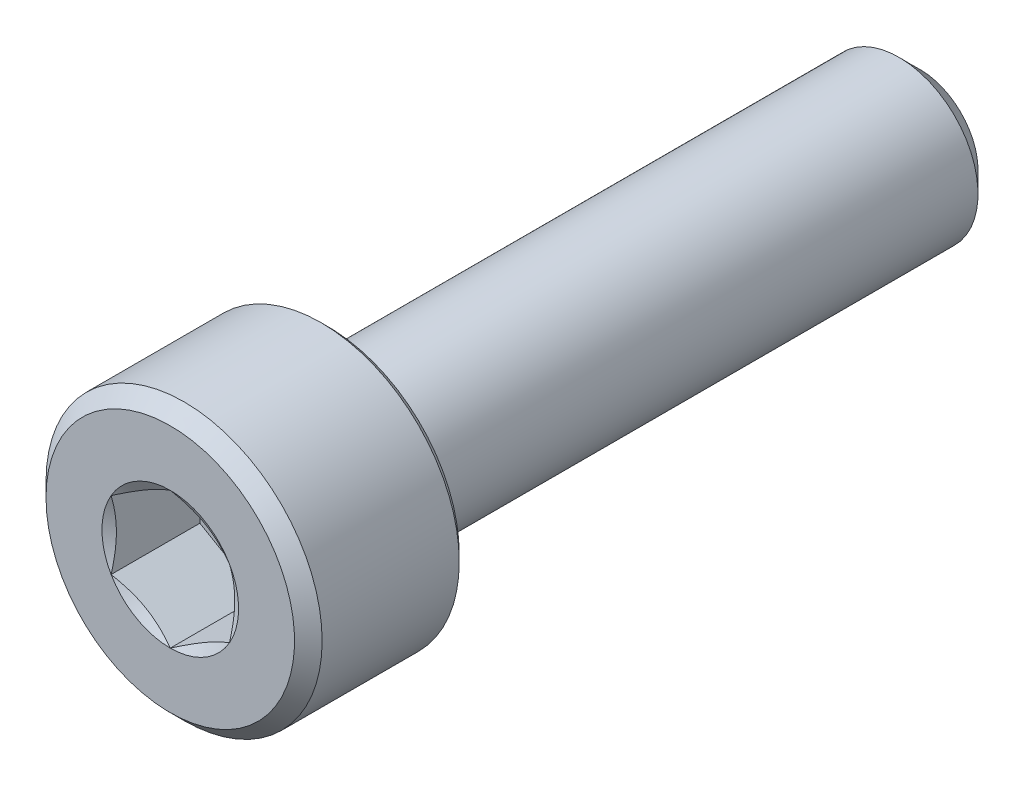
from build123d import *

# Parameters (mm, degrees)
CUT_EXTRUDE1_DEPTH = 2.25
CHAMFER1_SIZE      = 0.35
CHAMFER2_SIZE      = 0.175


with BuildPart() as part:
    # Sketch2 → Revolve1 (revolve)
    with BuildSketch(Plane(origin=(0, 0, 0), x_dir=(0, 0, -1), z_dir=(1, 0, 0))):
        Polygon((9.5, 1.475), (8.975, 2), (-5.5, 2), (-5.5, 3.5), (-9.5, 3.5), (-9.5, 0), (9.5, 0), align=None)
    revolve(axis=Axis((0, 0, -9.5), (0, 0, 1)))

    # Sketch4 → Cut-Extrude1 (cut)
    with BuildSketch(Plane.XY.offset(9.5)):
        Polygon((0, 1.732050808), (-1.5, 0.866025404), (-1.5, -0.866025404), (0, -1.732050808), (1.5, -0.866025404), (1.5, 0.866025404), align=None)
    extrude(amount=-CUT_EXTRUDE1_DEPTH, mode=Mode.SUBTRACT)

    # Cut-Extrude2 cone 1 section (through the dimple's axis) → Cut-Extrude2 (revolve, cut)
    with BuildSketch(Plane(origin=(0, 0, 9.5), x_dir=(0, -1, 0), z_dir=(1, 0, 0))):
        Polygon((0, 0), (1.732050808, 0), (0, 1), align=None)
    revolve(axis=Axis((0, 0, 9.5), (0, 0, -1)), mode=Mode.SUBTRACT)

    # Chamfer1
    chamfer1_edges = [part.edges().sort_by_distance(p)[0] for p in [
        (0, -3.5, 9.5),
    ]]
    chamfer(chamfer1_edges, length=CHAMFER1_SIZE)

    # Chamfer2
    chamfer2_edges = [part.edges().sort_by_distance(p)[0] for p in [
        (0, -3.5, 5.5),
    ]]
    chamfer(chamfer2_edges, length=CHAMFER2_SIZE)


solid = part.part
